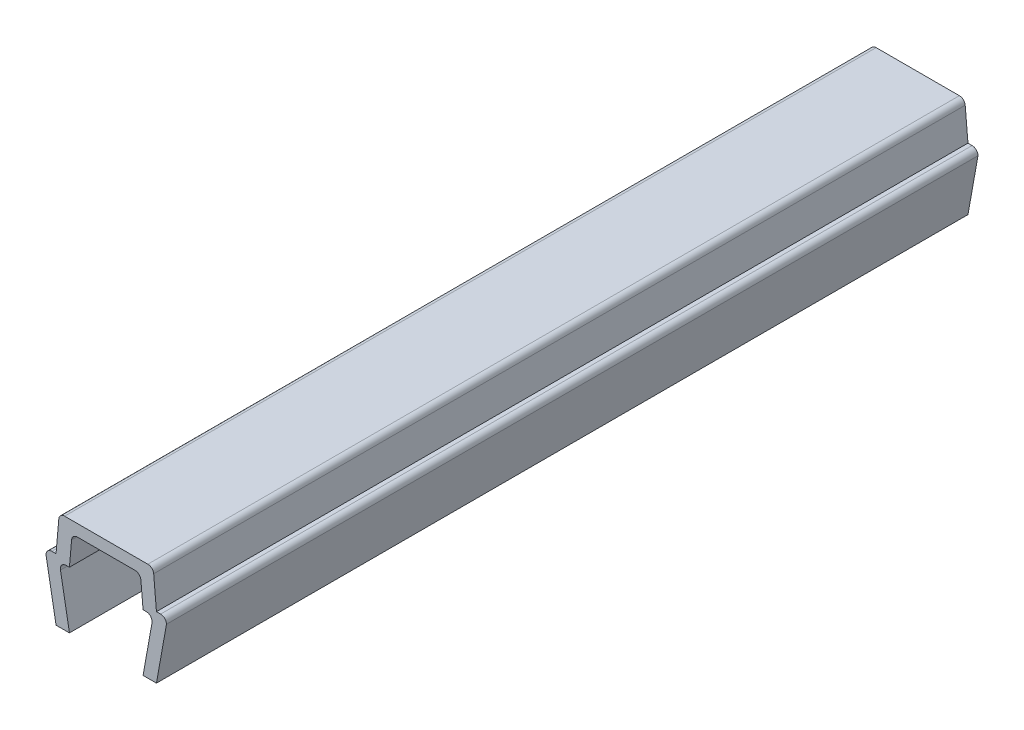
from build123d import *

# Parameters (mm, degrees)
BOSS_EXTRUDE1_DEPTH = 24.25


with BuildPart() as part:
    # Sketch1 → Boss-Extrude1 (new body, symmetric)
    with BuildSketch(Plane.XY):
        with BuildLine():
            Line((-3.6, 3.35), (-3, 0))
            Line((-3, 0), (-2.2, 0))
            Line((-2.2, 0), (-2.735217071, 2.988295315))
            ThreePointArc((-2.735217071, 2.988295315), (-2.659117427, 3.274614514), (-2.390699246, 3.4))
            Line((-2.390699246, 3.4), (-2.2, 3.4))
            Line((-2.2, 3.4), (-2.070472639, 4.88050451))
            ThreePointArc((-2.070472639, 4.88050451), (-1.958261067, 5.108047068), (-1.721804495, 5.2))
            Line((-1.721804495, 5.2), (1.721804495, 5.2))
            ThreePointArc((1.721804495, 5.2), (1.958261067, 5.108047068), (2.070472639, 4.88050451))
            Line((2.070472639, 4.88050451), (2.2, 3.4))
            Line((2.2, 3.4), (2.390699246, 3.4))
            ThreePointArc((2.390699246, 3.4), (2.659117427, 3.274614514), (2.735217071, 2.988295315))
            Line((2.735217071, 2.988295315), (2.2, 0))
            Line((2.2, 0), (3, 0))
            Line((3, 0), (3.6, 3.35))
            ThreePointArc((3.6, 3.35), (3.497487373, 3.597487373), (3.25, 3.7))
            Line((3.25, 3.7), (3, 3.7))
            Line((3, 3.7), (2.835477174, 5.58050451))
            ThreePointArc((2.835477174, 5.58050451), (2.723265602, 5.808047068), (2.486809029, 5.9))
            Line((2.486809029, 5.9), (-2.486809029, 5.9))
            ThreePointArc((-2.486809029, 5.9), (-2.723265602, 5.808047068), (-2.835477174, 5.58050451))
            Line((-2.835477174, 5.58050451), (-3, 3.7))
            Line((-3, 3.7), (-3.25, 3.7))
            ThreePointArc((-3.25, 3.7), (-3.497487373, 3.597487373), (-3.6, 3.35))
        make_face()
    extrude(amount=BOSS_EXTRUDE1_DEPTH, both=True)


solid = part.part
